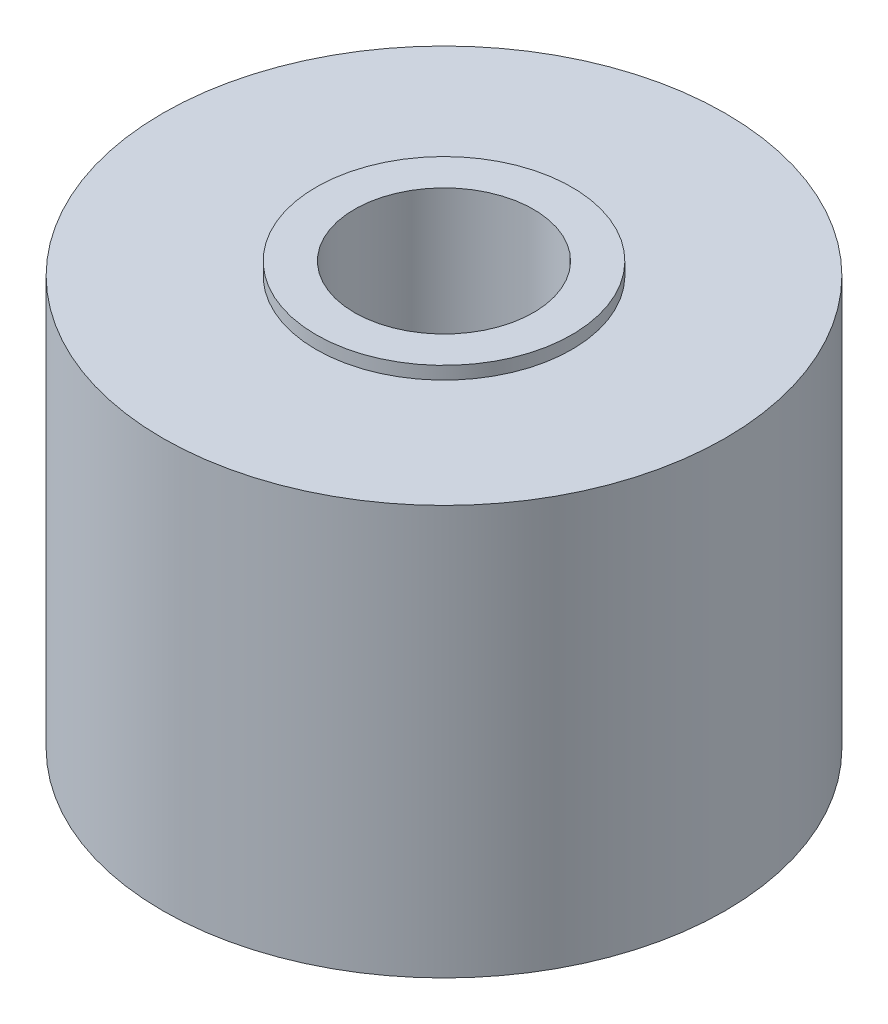
from build123d import *

# Parameters (mm, degrees)
SKETCH1_R           = 11
BOSS_EXTRUDE1_DEPTH = 16
SKETCH2_R           = 5
BOSS_EXTRUDE2_DEPTH = 0.5
SKETCH3_R           = 9
BOSS_EXTRUDE3_DEPTH = 0.5
SKETCH4_R           = 3.5
CUT_EXTRUDE1_DEPTH  = 18


with BuildPart() as part:
    # Sketch1 → Boss-Extrude1 (new body)
    with BuildSketch(Plane(origin=(0, 0, 0), x_dir=(1, 0, 0), z_dir=(0, 1, 0))):
        Circle(SKETCH1_R)
    extrude(amount=BOSS_EXTRUDE1_DEPTH)

    # Sketch2 → Boss-Extrude2 (add)
    with BuildSketch(Plane(origin=(0, 16, 0), x_dir=(1, 0, 0), z_dir=(0, 1, 0))):
        Circle(SKETCH2_R)
    extrude(amount=BOSS_EXTRUDE2_DEPTH)

    # Sketch3 → Boss-Extrude3 (add)
    with BuildSketch(Plane.XZ):
        Circle(SKETCH3_R)
    extrude(amount=BOSS_EXTRUDE3_DEPTH)

    # Sketch4 → Cut-Extrude1 (cut, through all)
    with BuildSketch(Plane(origin=(0, 16.5, 0), x_dir=(1, 0, 0), z_dir=(0, 1, 0))):
        Circle(SKETCH4_R)
    extrude(amount=-CUT_EXTRUDE1_DEPTH, mode=Mode.SUBTRACT)


solid = part.part
